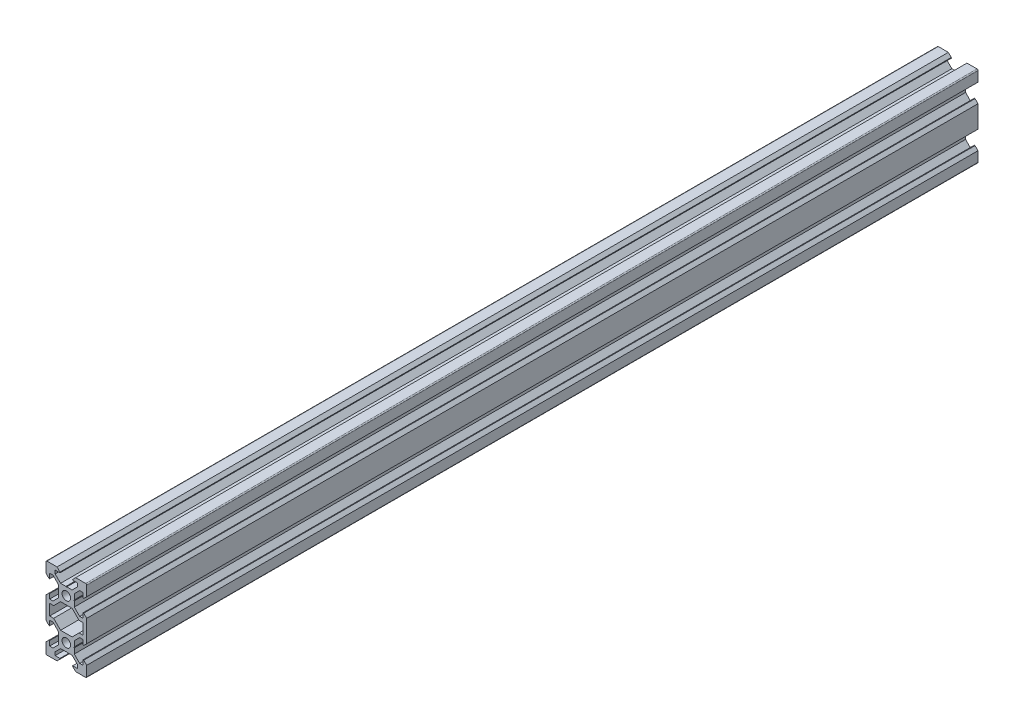
from build123d import *

# Parameters (mm, degrees)
SKETCH1_R           = 2.1
BOSS_EXTRUDE1_DEPTH = 438


with BuildPart() as part:
    # Sketch1 → Boss-Extrude1 (new body)
    with BuildSketch(Plane.XY):
        with BuildLine():
            Line((4.58, -20), (9.5, -20))
            ThreePointArc((9.5, -20), (9.853553391, -19.853553391), (10, -19.5))
            Line((10, -19.5), (10, -14.58))
            Line((10, -14.58), (8.545, -13.125))
            Line((8.545, -13.125), (8.2, -13.125))
            Line((8.2, -13.125), (8.2, -15.5))
            Line((8.2, -15.5), (6.560660172, -15.5))
            Line((6.560660172, -15.5), (3.9, -12.839339828))
            Line((3.9, -12.839339828), (3.9, -10.21))
            Line((3.9, -10.21), (3.69, -10))
            Line((3.69, -10), (3.9, -9.79))
            Line((3.9, -9.79), (3.9, -7.160660172))
            Line((3.9, -7.160660172), (6.560660172, -4.5))
            Line((6.560660172, -4.5), (8.2, -4.5))
            Line((8.2, -4.5), (8.2, -6.875))
            Line((8.2, -6.875), (8.545, -6.875))
            Line((8.545, -6.875), (10, -5.42))
            Line((10, -5.42), (10, 5.42))
            Line((10, 5.42), (8.545, 6.875))
            Line((8.545, 6.875), (8.2, 6.875))
            Line((8.2, 6.875), (8.2, 4.5))
            Line((8.2, 4.5), (6.560660172, 4.5))
            Line((6.560660172, 4.5), (3.9, 7.160660172))
            Line((3.9, 7.160660172), (3.9, 9.79))
            Line((3.9, 9.79), (3.69, 10))
            Line((3.69, 10), (3.9, 10.21))
            Line((3.9, 10.21), (3.9, 12.839339828))
            Line((3.9, 12.839339828), (6.560660172, 15.5))
            Line((6.560660172, 15.5), (8.2, 15.5))
            Line((8.2, 15.5), (8.2, 13.125))
            Line((8.2, 13.125), (8.545, 13.125))
            Line((8.545, 13.125), (10, 14.58))
            Line((10, 14.58), (10, 19.5))
            ThreePointArc((10, 19.5), (9.853553391, 19.853553391), (9.5, 20))
            Line((9.5, 20), (4.58, 20))
            Line((4.58, 20), (3.125, 18.545))
            Line((3.125, 18.545), (3.125, 18.2))
            Line((3.125, 18.2), (5.5, 18.2))
            Line((5.5, 18.2), (5.5, 16.560660172))
            Line((5.5, 16.560660172), (2.839339828, 13.9))
            Line((2.839339828, 13.9), (0.21, 13.9))
            Line((0.21, 13.9), (0, 13.69))
            Line((0, 13.69), (-0.21, 13.9))
            Line((-0.21, 13.9), (-2.839339828, 13.9))
            Line((-2.839339828, 13.9), (-5.5, 16.560660172))
            Line((-5.5, 16.560660172), (-5.5, 18.2))
            Line((-5.5, 18.2), (-3.125, 18.2))
            Line((-3.125, 18.2), (-3.125, 18.545))
            Line((-3.125, 18.545), (-4.58, 20))
            Line((-4.58, 20), (-9.5, 20))
            ThreePointArc((-9.5, 20), (-9.853553391, 19.853553391), (-10, 19.5))
            Line((-10, 19.5), (-10, 14.58))
            Line((-10, 14.58), (-8.545, 13.125))
            Line((-8.545, 13.125), (-8.2, 13.125))
            Line((-8.2, 13.125), (-8.2, 15.5))
            Line((-8.2, 15.5), (-6.560660172, 15.5))
            Line((-6.560660172, 15.5), (-3.9, 12.839339828))
            Line((-3.9, 12.839339828), (-3.9, 10.21))
            Line((-3.9, 10.21), (-3.69, 10))
            Line((-3.69, 10), (-3.9, 9.79))
            Line((-3.9, 9.79), (-3.9, 7.160660172))
            Line((-3.9, 7.160660172), (-6.560660172, 4.5))
            Line((-6.560660172, 4.5), (-8.2, 4.5))
            Line((-8.2, 4.5), (-8.2, 6.875))
            Line((-8.2, 6.875), (-8.545, 6.875))
            Line((-8.545, 6.875), (-10, 5.42))
            Line((-10, 5.42), (-10, -5.42))
            Line((-10, -5.42), (-8.545, -6.875))
            Line((-8.545, -6.875), (-8.2, -6.875))
            Line((-8.2, -6.875), (-8.2, -4.5))
            Line((-8.2, -4.5), (-6.560660172, -4.5))
            Line((-6.560660172, -4.5), (-3.9, -7.160660172))
            Line((-3.9, -7.160660172), (-3.9, -9.79))
            Line((-3.9, -9.79), (-3.69, -10))
            Line((-3.69, -10), (-3.9, -10.21))
            Line((-3.9, -10.21), (-3.9, -12.839339828))
            Line((-3.9, -12.839339828), (-6.560660172, -15.5))
            Line((-6.560660172, -15.5), (-8.2, -15.5))
            Line((-8.2, -15.5), (-8.2, -13.125))
            Line((-8.2, -13.125), (-8.545, -13.125))
            Line((-8.545, -13.125), (-10, -14.58))
            Line((-10, -14.58), (-10, -19.5))
            ThreePointArc((-10, -19.5), (-9.853553391, -19.853553391), (-9.5, -20))
            Line((-9.5, -20), (-4.58, -20))
            Line((-4.58, -20), (-3.125, -18.545))
            Line((-3.125, -18.545), (-3.125, -18.2))
            Line((-3.125, -18.2), (-5.5, -18.2))
            Line((-5.5, -18.2), (-5.5, -16.560660172))
            Line((-5.5, -16.560660172), (-2.839339828, -13.9))
            Line((-2.839339828, -13.9), (-0.21, -13.9))
            Line((-0.21, -13.9), (0, -13.69))
            Line((0, -13.69), (0.21, -13.9))
            Line((0.21, -13.9), (2.839339828, -13.9))
            Line((2.839339828, -13.9), (5.5, -16.560660172))
            Line((5.5, -16.560660172), (5.5, -18.2))
            Line((5.5, -18.2), (3.125, -18.2))
            Line((3.125, -18.2), (3.125, -18.545))
            Line((3.125, -18.545), (4.58, -20))
        make_face()
        with Locations((0, -10)):
            Circle(SKETCH1_R, mode=Mode.SUBTRACT)
        Polygon((-6.239339828, -2.7), (-8.2, -2.7), (-8.2, 2.7), (-6.239339828, 2.7), (-2.839339828, 6.1), (2.839339828, 6.1), (6.239339828, 2.7), (8.2, 2.7), (8.2, -2.7), (6.239339828, -2.7), (2.839339828, -6.1), (-2.839339828, -6.1), align=None, mode=Mode.SUBTRACT)
        with Locations((0, 10)):
            Circle(SKETCH1_R, mode=Mode.SUBTRACT)
    extrude(amount=BOSS_EXTRUDE1_DEPTH)


solid = part.part
